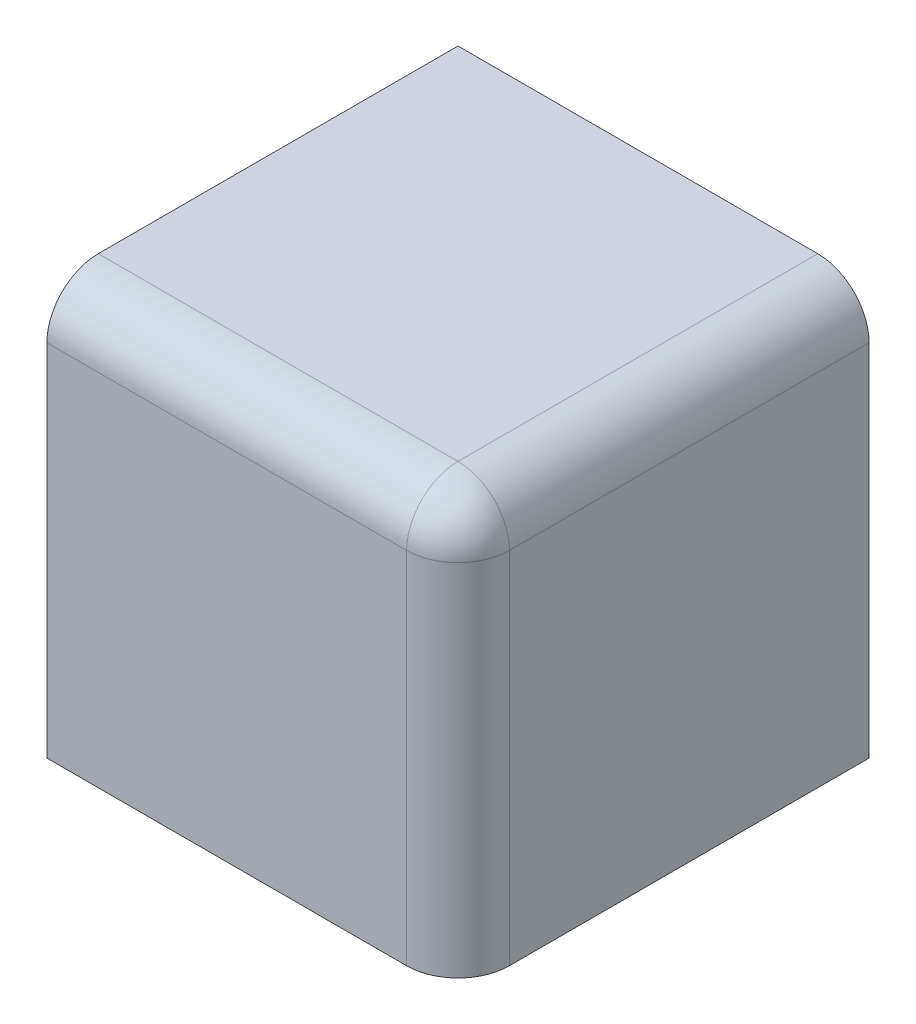
from build123d import *

# Parameters (mm, degrees)
SKETCH1_W           = 20
SKETCH1_H           = 20
BOSS_EXTRUDE1_DEPTH = 20
SKETCH2_W           = 17.5
SKETCH2_H           = 17.5
CUT_EXTRUDE1_DEPTH  = 17.5
FILLET1_R           = 2.5


with BuildPart() as part:
    # Sketch1 → Boss-Extrude1 (new body)
    with BuildSketch(Plane(origin=(0, 20, 0), x_dir=(1, 0, 0), z_dir=(0, 1, 0))):
        with Locations((10, -10)):
            Rectangle(SKETCH1_W, SKETCH1_H)
    extrude(amount=-BOSS_EXTRUDE1_DEPTH)

    # Sketch2 → Cut-Extrude1 (cut)
    with BuildSketch(Plane(origin=(0, 0, 0), x_dir=(-1, 0, 0), z_dir=(0, 0, -1))):
        with Locations((-8.75, 8.75)):
            Rectangle(SKETCH2_W, SKETCH2_H)
    extrude(amount=-CUT_EXTRUDE1_DEPTH, mode=Mode.SUBTRACT)

    # Fillet1
    fillet1_edges = [part.edges().sort_by_distance(p)[0] for p in [
        (20, 20, 10),
        (10, 20, 20),
        (20, 10, 20),
    ]]
    fillet(fillet1_edges, radius=FILLET1_R)


solid = part.part
